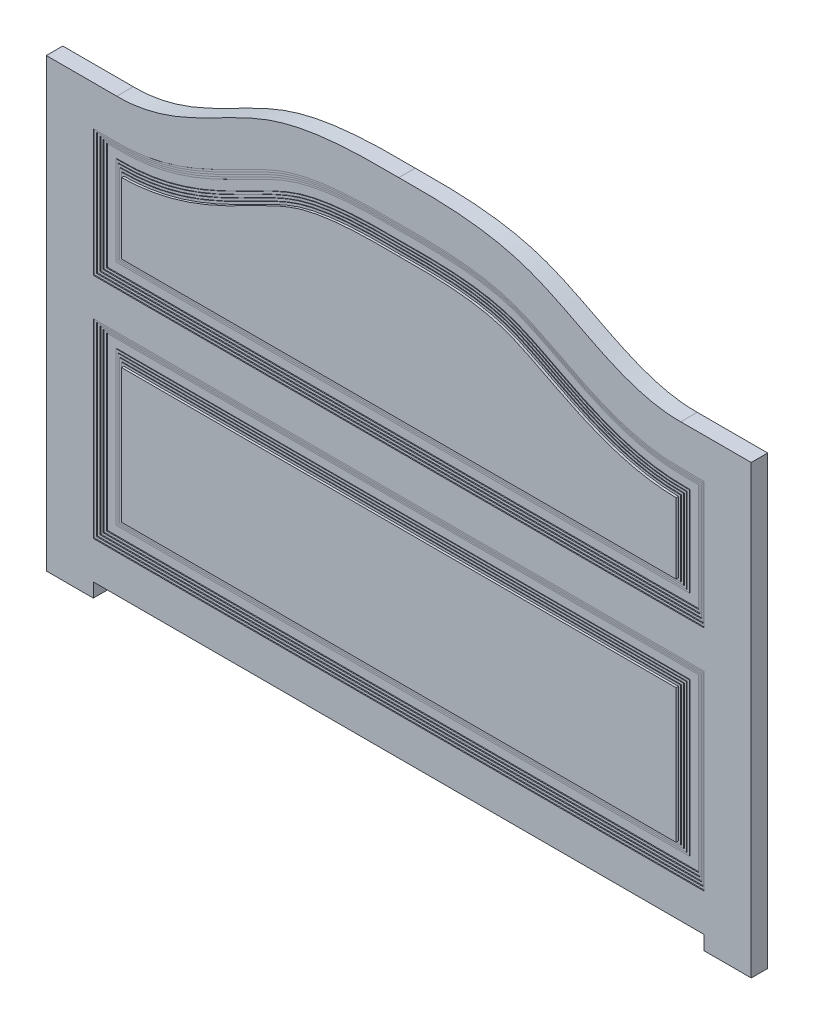
from build123d import *

# Parameters (mm, degrees)
BOSS_EXTRUDE1_DEPTH  = 35
CUT_EXTRUDE1_DEPTH   = 2
CUT_EXTRUDE2_DEPTH   = 2
CUT_EXTRUDE3_DEPTH   = 2
CUT_EXTRUDE4_DEPTH   = 2
CUT_EXTRUDE5_DEPTH   = 2
BOSS_EXTRUDE2_DEPTH  = 1.25
BOSS_EXTRUDE3_DEPTH  = 1.25
BOSS_EXTRUDE4_DEPTH  = 1.25
BOSS_EXTRUDE5_DEPTH  = 1.25
BOSS_EXTRUDE6_DEPTH  = 5
SKETCH12_W           = 1300
SKETCH12_H           = 30
CUT_EXTRUDE6_DEPTH   = 36.0000001
SKETCH13_W           = 1300
SKETCH13_H           = 405
CUT_EXTRUDE7_DEPTH   = 2
SKETCH14_W           = 1290
SKETCH14_H           = 395
CUT_EXTRUDE8_DEPTH   = 2
SKETCH15_W           = 1280
SKETCH15_H           = 385
CUT_EXTRUDE9_DEPTH   = 2
SKETCH16_W           = 1270
SKETCH16_H           = 375
CUT_EXTRUDE10_DEPTH  = 2
SKETCH17_W           = 1260
SKETCH17_H           = 365
CUT_EXTRUDE11_DEPTH  = 2
SKETCH18_W           = 1220
SKETCH18_H           = 325
BOSS_EXTRUDE7_DEPTH  = 1.25
SKETCH19_W           = 1210
SKETCH19_H           = 315
BOSS_EXTRUDE8_DEPTH  = 1.25
SKETCH20_W           = 1200
SKETCH20_H           = 305
BOSS_EXTRUDE9_DEPTH  = 1.25
SKETCH21_W           = 1190
SKETCH21_H           = 295
BOSS_EXTRUDE10_DEPTH = 1.25
SKETCH22_W           = 1180
SKETCH22_H           = 285
BOSS_EXTRUDE11_DEPTH = 5


with BuildPart() as part:
    # Sketch1 → Boss-Extrude1 (new body)
    with BuildSketch(Plane.XY):
        with BuildLine():
            Line((0, 0), (0, 150))
            add(Edge.make_bspline(
                [(0, 150), (-88.817406594, 150.972834744), (-307.790292815, 146.939990671), (-474.88994394, -1.348363378), (-600, 0)],
                knots=[0, 0, 0, 0, 0.436252435, 1, 1, 1, 1], degree=3))
            Line((-600, 0), (-750, 0))
            Line((-750, 0), (-750, -950))
            Line((-750, -950), (0, -950))
            Line((0, -950), (0, 0))
        make_face()
    boss_extrude1 = extrude(amount=BOSS_EXTRUDE1_DEPTH)

    # Mirror1: Boss-Extrude1 across plane
    add(boss_extrude1.mirror(Plane(origin=(0, 0, 0), x_dir=(0, 0, 1), z_dir=(1, 0, 0))))

    # Sketch2 → Cut-Extrude1 (cut)
    with BuildSketch(Plane.XY.offset(35)):
        with BuildLine():
            Line((-650, -355), (-650, -85))
            Line((-650, -85), (-600.427478486, -85))
            add(Edge.make_bspline(
                [(0, 64.994901319), (-6.499864474, 65.066095629), (-12.999339965, 65.125184784), (-25.996628916, 65.191640606), (-32.494485815, 65.200359117), (-51.984764082, 65.124054121), (-64.973907821, 64.937030663), (-90.938277662, 64.129866445), (-103.913521787, 63.510286532), (-123.361583263, 62.120193531), (-129.841796022, 61.579825813), (-139.557768111, 60.63399387), (-142.79703468, 60.2959783), (-149.26089955, 59.572743903), (-152.486735704, 59.187423069), (-168.583364413, 57.134249562), (-181.356982287, 55.088561066), (-206.636866058, 49.957662736), (-219.143373755, 46.873393072), (-234.562103747, 42.184405198), (-237.635079352, 41.204730045), (-243.75808105, 39.156147154), (-246.807839347, 38.086198168), (-255.925186426, 34.752209092), (-261.961183487, 32.365333669), (-273.968396946, 27.339701834), (-279.942981126, 24.699326), (-291.823088426, 19.246149426), (-297.729902726, 16.432962323), (-315.385232858, 7.823762056), (-327.069604167, 1.860632515), (-350.422387358, -10.107205823), (-362.090469323, -16.112774157), (-385.538220873, -27.833190467), (-397.317701282, -33.548531303), (-421.09610066, -44.407507465), (-433.094876365, -49.551516037), (-457.404681475, -59.026015444), (-469.715561428, -63.356895647), (-494.73157389, -70.991505865), (-507.436529994, -74.295695467), (-533.316708495, -79.678885117), (-546.491729222, -81.758410581), (-561.620746224, -83.297737299), (-563.305297505, -83.457562009), (-566.673089318, -83.753813308), (-571.726324374, -84.163461637), (-576.784220493, -84.468496437), (-586.906272008, -84.938081958), (-593.662653708, -85.063789778), (-600.427478486, -85)],
                knots=[0, 0, 0, 0, 0.03125, 0.03125, 0.0625, 0.0625, 0.125, 0.125, 0.1875, 0.1875, 0.21875, 0.21875, 0.234375, 0.234375, 0.25, 0.25, 0.3125, 0.3125, 0.375, 0.375, 0.390625, 0.390625, 0.40625, 0.40625, 0.4375, 0.4375, 0.46875, 0.46875, 0.5, 0.5, 0.5625, 0.5625, 0.625, 0.625, 0.6875, 0.6875, 0.75, 0.75, 0.8125, 0.8125, 0.875, 0.875, 0.9375, 0.9375, 0.9453125, 0.9453125, 0.953125, 0.96875, 0.96875, 1, 1, 1, 1], degree=3))
            add(Edge.make_bspline(
                [(600.427478486, -85), (587.134222228, -85.125350456), (573.97860065, -84.517793446), (547.923518621, -81.938616236), (535.024130317, -79.966611847), (509.45968606, -74.774778549), (496.79472732, -71.554431977), (477.952631083, -65.896713501), (471.697771026, -63.873215801), (462.351104985, -60.648270489), (459.241482512, -59.541696046), (453.033523317, -57.2684503), (449.935817529, -56.101953999), (434.519710085, -50.145874903), (422.380684539, -44.970816881), (398.371834421, -34.051090856), (386.502227031, -28.305963308), (362.89999974, -16.525852499), (351.167679527, -10.490235115), (327.686310086, 1.545602251), (315.937793309, 7.546948862), (298.162205757, 16.225628715), (292.21123464, 19.06398338), (283.224855611, 23.194723971), (280.219378922, 24.550442219), (274.184436702, 27.211120045), (271.160911312, 28.513439713), (262.071701262, 32.321645385), (255.986439257, 34.729396534), (246.808401626, 38.086198457), (243.740633522, 39.162332384), (237.586599575, 41.220598478), (234.50054899, 42.20382454), (219.028115751, 46.905603066), (206.515952078, 49.984961905), (181.286274834, 55.10013306), (168.568520586, 57.134722298), (142.975224901, 60.402058292), (130.099525585, 61.634002739), (110.696588611, 63.027667727), (104.213988732, 63.416228399), (91.223213634, 64.063381065), (84.712332243, 64.322037945), (65.166579635, 64.933719685), (52.134521088, 65.122688506), (32.584969424, 65.200389606), (26.06820733, 65.191871598), (13.034332123, 65.125497593), (6.517209362, 65.066285611), (0, 64.994901319)],
                knots=[0, 0, 0, 0, 0.0625, 0.0625, 0.125, 0.125, 0.1875, 0.1875, 0.21875, 0.21875, 0.234375, 0.234375, 0.25, 0.25, 0.3125, 0.3125, 0.375, 0.375, 0.4375, 0.4375, 0.5, 0.5, 0.53125, 0.53125, 0.546875, 0.546875, 0.5625, 0.5625, 0.59375, 0.59375, 0.609375, 0.609375, 0.625, 0.625, 0.6875, 0.6875, 0.75, 0.75, 0.8125, 0.8125, 0.84375, 0.84375, 0.875, 0.875, 0.9375, 0.9375, 0.96875, 0.96875, 1, 1, 1, 1], degree=3))
            Line((600.427478486, -85), (650, -85))
            Line((650, -85), (650, -355))
            Line((650, -355), (-650, -355))
        make_face()
    extrude(amount=-CUT_EXTRUDE1_DEPTH, mode=Mode.SUBTRACT)

    # Sketch3 → Cut-Extrude2 (cut)
    with BuildSketch(Plane.XY.offset(33)):
        with BuildLine():
            Line((-600.427478486, -90), (-645, -90))
            Line((-645, -90), (-645, -350))
            Line((-645, -350), (645, -350))
            Line((645, -350), (645, -90))
            Line((645, -90), (600.474624528, -89.99977772))
            add(Edge.make_bspline(
                [(600.474624528, -89.99977772), (587.283330747, -90.124166708), (574.22142551, -89.53671532), (548.339339258, -87.031949381), (535.519249318, -85.114133762), (510.101302776, -80.055869856), (491.204775132, -75.343782092), (472.530816357, -69.407215703), (463.228042857, -66.250746363), (460.132823693, -65.167201602), (453.953262909, -62.940268484), (450.874141978, -61.798715214), (435.542752146, -55.964976804), (423.468365501, -50.887796985), (399.590000138, -40.151876173), (387.786614175, -34.491860357), (364.325901096, -22.857702747), (352.669536068, -16.881491811), (329.3574474, -4.927690516), (317.700174426, 1.054811947), (294.237145996, 12.62513653), (282.432843165, 18.21754321), (264.473177128, 25.935608893), (258.444117741, 28.395740121), (249.314508964, 31.858143381), (246.256930117, 32.974208118), (240.108921248, 35.119342556), (237.018096098, 36.147365896), (221.48170474, 41.069630424), (208.793457137, 44.321213412), (192.674799168, 47.701545093), (189.434911338, 48.344133292), (182.953133154, 49.56059053), (179.710134783, 50.134763244), (169.975260873, 51.762363805), (163.477509984, 52.720929681), (143.964210576, 55.272957571), (130.928669165, 56.543619279), (104.818479635, 58.45353541), (91.743806676, 59.092388781), (65.566928559, 59.925567413), (52.464692036, 60.119386273), (32.798351339, 60.2004472), (26.240733507, 60.19241616), (13.122388172, 60.126146097), (6.561571761, 60.066471599), (0, 59.994601396)],
                knots=[0, 0, 0, 0, 0.0625, 0.0625, 0.125, 0.125, 0.1875, 0.21875, 0.21875, 0.234375, 0.234375, 0.25, 0.25, 0.3125, 0.3125, 0.375, 0.375, 0.4375, 0.4375, 0.5, 0.5, 0.5625, 0.5625, 0.59375, 0.59375, 0.609375, 0.609375, 0.625, 0.625, 0.6875, 0.6875, 0.703125, 0.703125, 0.71875, 0.71875, 0.75, 0.75, 0.8125, 0.8125, 0.875, 0.875, 0.9375, 0.9375, 0.96875, 0.96875, 1, 1, 1, 1], degree=3))
            add(Edge.make_bspline(
                [(0, 59.994601396), (-6.551716083, 60.066365894), (-13.102913006, 60.12597926), (-26.203046748, 60.192307382), (-32.752044784, 60.200454971), (-52.394560518, 60.120079641), (-65.483617124, 59.927143199), (-91.642737272, 59.096730442), (-104.71281737, 58.459641617), (-130.825947712, 56.552819967), (-143.8690242, 55.283701405), (-160.149769373, 53.156628685), (-163.404755441, 52.704032852), (-169.891335454, 51.743320988), (-179.593610165, 50.21803681), (-189.207733344, 48.423728544), (-208.304349931, 44.433399428), (-220.859576587, 41.236511254), (-236.274775521, 36.389443989), (-239.343722138, 35.377020481), (-245.452180582, 33.262343291), (-248.492010193, 32.161059435), (-257.573403808, 28.740947472), (-263.577014628, 26.306292441), (-281.47422698, 18.655577324), (-293.25509218, 13.09546435), (-310.826579214, 4.450688716), (-316.667354009, 1.51690544), (-328.326452076, -4.399815439), (-334.145655177, -7.382930432), (-351.602547222, -16.333991585), (-363.23860641, -22.305837236), (-386.641993368, -33.935444216), (-398.408408405, -39.595389429), (-422.184595457, -50.333003344), (-434.193712765, -55.412238556), (-458.552786096, -64.755189414), (-470.902266859, -69.020042211), (-489.747995962, -74.648054242), (-499.251130282, -77.270000013), (-508.886495193, -79.57555968), (-515.340783696, -81.039115577), (-518.578382515, -81.732948386), (-534.774574766, -84.998123894), (-547.80092248, -86.966086092), (-574.001590243, -89.528395002), (-587.175854245, -90.12326199), (-600.427478486, -90)],
                knots=[0, 0, 0, 0, 0.03125, 0.03125, 0.0625, 0.0625, 0.125, 0.125, 0.1875, 0.1875, 0.25, 0.25, 0.265625, 0.265625, 0.28125, 0.3125, 0.3125, 0.375, 0.375, 0.390625, 0.390625, 0.40625, 0.40625, 0.4375, 0.4375, 0.5, 0.5, 0.53125, 0.53125, 0.5625, 0.5625, 0.625, 0.625, 0.6875, 0.6875, 0.75, 0.75, 0.8125, 0.8125, 0.84375, 0.859375, 0.859375, 0.875, 0.875, 0.9375, 0.9375, 1, 1, 1, 1], degree=3))
        make_face()
    extrude(amount=-CUT_EXTRUDE2_DEPTH, mode=Mode.SUBTRACT)

    # Sketch4 → Cut-Extrude3 (cut)
    with BuildSketch(Plane.XY.offset(31)):
        with BuildLine():
            Line((-600.427478486, -95), (-640, -95))
            Line((-640, -95), (-640, -345))
            Line((-640, -345), (640, -345))
            Line((640, -345), (640, -94.999975039))
            Line((640, -94.999975039), (600.52177057, -94.99955544))
            add(Edge.make_bspline(
                [(600.52177057, -94.99955544), (587.270187276, -95.124512936), (574.165463522, -94.540719011), (548.228501892, -92.05810081), (535.396377304, -90.158729807), (509.981365194, -85.157157358), (497.398708861, -82.053840188), (472.454697339, -74.779195565), (460.093654017, -70.606363026), (444.758520601, -64.829676618), (441.697287375, -63.646379824), (435.585752702, -61.227028931), (432.533906916, -59.990347047), (423.412525699, -56.214413513), (417.372779628, -53.607665623), (399.356594076, -45.563523169), (387.484053812, -39.900390535), (363.891578652, -28.242565114), (352.172857836, -22.245234534), (328.743715524, -10.232541744), (317.035250325, -4.212929158), (293.448531292, 7.457402395), (281.573024824, 13.114090463), (263.457914807, 20.943303313), (257.368995826, 23.443215001), (248.130670941, 26.965069262), (245.033712131, 28.100961734), (238.799231642, 30.284617203), (235.661171879, 31.331211125), (230.923178819, 32.833959274), (229.339258339, 33.323692568), (226.171663236, 34.278776271), (221.416864913, 35.676010272), (216.652238575, 36.971112025), (207.110865648, 39.435362488), (200.733804854, 40.910412784), (181.561378787, 44.906961322), (168.725017542, 47.002431447), (142.971090581, 50.349498796), (130.053485318, 51.600685071), (104.15849647, 53.48184423), (91.181061034, 54.11127828), (65.183992269, 54.931627947), (52.16430697, 55.1220035), (32.614846945, 55.200433663), (26.095030283, 55.191971987), (13.050615183, 55.125356658), (6.525879882, 55.065780736), (-8.57e-07, 54.994301464)],
                knots=[0, 0, 0, 0, 0.0625, 0.0625, 0.125, 0.125, 0.1875, 0.1875, 0.25, 0.25, 0.265625, 0.265625, 0.28125, 0.28125, 0.3125, 0.3125, 0.375, 0.375, 0.4375, 0.4375, 0.5, 0.5, 0.5625, 0.5625, 0.59375, 0.59375, 0.609375, 0.609375, 0.625, 0.625, 0.6328125, 0.6328125, 0.640625, 0.65625, 0.65625, 0.6875, 0.6875, 0.75, 0.75, 0.8125, 0.8125, 0.875, 0.875, 0.9375, 0.9375, 0.96875, 0.96875, 1, 1, 1, 1], degree=3))
            add(Edge.make_bspline(
                [(-8.57e-07, 54.994301464), (-6.55136629, 55.066064308), (-13.102225898, 55.125844938), (-26.201703934, 55.19231607), (-32.75038526, 55.20049653), (-52.391992318, 55.119934011), (-65.480498541, 54.926499616), (-91.638639621, 54.09259693), (-104.708288823, 53.452468435), (-130.820645472, 51.534002379), (-143.86337376, 50.25615846), (-160.143656652, 48.110999134), (-163.395958207, 47.654771239), (-169.877870238, 46.685922789), (-173.109534009, 46.173044291), (-182.774812449, 44.543423446), (-189.178729711, 43.335743099), (-208.257045214, 39.304099781), (-220.797698578, 36.070589571), (-236.188832495, 31.156959631), (-239.252568161, 30.129859627), (-245.350666555, 27.9857152), (-248.385439785, 26.869927794), (-257.452298455, 23.407854214), (-263.446915222, 20.946833237), (-281.320558099, 13.226298349), (-293.089448031, 7.629530635), (-310.649736837, -1.050542282), (-316.48725812, -3.993071264), (-328.141783497, -9.92094136), (-333.959970964, -12.906624308), (-351.417032981, -21.857683059), (-363.057441846, -27.819382022), (-386.476295391, -39.411990346), (-398.253565357, -45.045714794), (-422.055369547, -55.720618586), (-434.0790739, -60.763786633), (-458.468206891, -70.031213221), (-470.833060149, -74.256850603), (-489.700250374, -79.828672198), (-496.042548922, -81.558373151), (-505.643471988, -83.94329854), (-508.858355059, -84.703345162), (-515.318582354, -86.150441171), (-518.556815586, -86.835902985), (-534.760226491, -90.062016117), (-547.791282051, -92.005232941), (-573.998789825, -94.534723612), (-587.175175679, -95.121616779), (-600.427478486, -95)],
                knots=[0, 0, 0, 0, 0.03125, 0.03125, 0.0625, 0.0625, 0.125, 0.125, 0.1875, 0.1875, 0.25, 0.25, 0.265625, 0.265625, 0.28125, 0.28125, 0.3125, 0.3125, 0.375, 0.375, 0.390625, 0.390625, 0.40625, 0.40625, 0.4375, 0.4375, 0.5, 0.5, 0.53125, 0.53125, 0.5625, 0.5625, 0.625, 0.625, 0.6875, 0.6875, 0.75, 0.75, 0.8125, 0.8125, 0.84375, 0.84375, 0.859375, 0.859375, 0.875, 0.875, 0.9375, 0.9375, 1, 1, 1, 1], degree=3))
        make_face()
    extrude(amount=-CUT_EXTRUDE3_DEPTH, mode=Mode.SUBTRACT)

    # Sketch5 → Cut-Extrude4 (cut)
    with BuildSketch(Plane.XY.offset(29)):
        with BuildLine():
            Line((-600.427478486, -100), (-635, -100))
            Line((-635, -100), (-635, -340))
            Line((-635, -340), (635, -340))
            Line((635, -340), (635, -99.999921896))
            Line((635, -99.999921896), (600.568916612, -99.99933316))
            add(Edge.make_bspline(
                [(600.568916612, -99.99933316), (587.265302227, -100.12478129), (574.103953031, -99.545404721), (548.045918633, -97.075426253), (535.14935047, -95.184244506), (509.599105501, -90.198523893), (496.945677091, -87.102754402), (471.855414853, -79.83814047), (459.418933799, -75.667548277), (443.987671521, -69.887837912), (440.907129328, -68.703605474), (434.756820662, -66.281754429), (431.6892047, -65.044935508), (422.52322897, -61.269020584), (416.455161389, -58.661763277), (398.357790679, -50.614247724), (386.436333014, -44.946104387), (362.754184616, -33.270105823), (350.994898897, -27.259281701), (327.489724888, -15.209323746), (315.746094546, -9.165418706), (292.088588821, 2.562651568), (280.177963655, 8.25368474), (265.030687509, 14.820202123), (261.988243003, 16.10605834), (255.872143659, 18.611821136), (252.795534266, 19.832787785), (246.634301049, 22.187180337), (243.547206418, 23.321644932), (237.358301431, 25.493503177), (234.256294136, 26.529597743), (218.709704812, 31.468953049), (206.15808015, 34.666116844), (180.885929456, 39.946301984), (168.165376434, 42.029145287), (142.597695451, 45.359891891), (129.750551002, 46.60768642), (103.962490632, 48.484720543), (91.021515504, 49.113569575), (71.560210303, 49.728061568), (65.064785238, 49.87798814), (52.060365995, 50.088333869), (45.550813003, 50.148734937), (32.536113877, 50.200467682), (26.028829298, 50.191773241), (13.014353183, 50.12489932), (6.507164364, 50.065275819), (-2.549e-06, 49.994001523)],
                knots=[0, 0, 0, 0, 0.0625, 0.0625, 0.125, 0.125, 0.1875, 0.1875, 0.25, 0.25, 0.265625, 0.265625, 0.28125, 0.28125, 0.3125, 0.3125, 0.375, 0.375, 0.4375, 0.4375, 0.5, 0.5, 0.5625, 0.5625, 0.578125, 0.578125, 0.59375, 0.59375, 0.609375, 0.609375, 0.625, 0.625, 0.6875, 0.6875, 0.75, 0.75, 0.8125, 0.8125, 0.875, 0.875, 0.90625, 0.90625, 0.9375, 0.9375, 0.96875, 0.96875, 1, 1, 1, 1], degree=3))
            add(Edge.make_bspline(
                [(-2.549e-06, 49.994001523), (-6.552182936, 50.065775423), (-13.103866919, 50.125731053), (-26.204995973, 50.192338788), (-32.754506063, 50.20053887), (-52.398607564, 50.119699913), (-65.488787882, 49.925642579), (-91.650257085, 49.087764847), (-104.721558048, 48.444232027), (-130.837102782, 46.51299475), (-143.881361475, 45.225645562), (-160.163353115, 43.060982529), (-163.413805551, 42.6007599), (-169.893186445, 41.622900505), (-173.123430951, 41.105100982), (-182.783937317, 39.459318527), (-189.183996346, 38.239026048), (-208.248081447, 34.162207816), (-220.775793186, 30.889061699), (-236.142815994, 25.903297972), (-239.201290811, 24.860515134), (-245.28904666, 22.685723881), (-248.318746531, 21.554995571), (-257.370867077, 18.04979074), (-263.356267838, 15.562169475), (-281.205254764, 7.771621137), (-292.961120656, 2.139466324), (-310.508301894, -6.573497085), (-316.341944814, -9.523796476), (-327.991411966, -15.461045476), (-333.80835205, -18.448393148), (-351.264843732, -27.396811057), (-362.909137165, -33.346489456), (-386.342186976, -44.898786855), (-398.129568354, -50.504709166), (-421.955036671, -61.114255935), (-433.99215766, -66.120201001), (-458.408486044, -75.310258904), (-470.787038184, -79.495945935), (-489.672769411, -85.010742701), (-499.194972881, -87.577538927), (-508.847214173, -89.831930828), (-515.312194224, -91.262420001), (-518.550194036, -91.939375285), (-534.75781541, -95.126148715), (-547.791173599, -97.044517636), (-574.000733006, -99.541088833), (-587.176859327, -100.119993801), (-600.427478486, -100)],
                knots=[0, 0, 0, 0, 0.03125, 0.03125, 0.0625, 0.0625, 0.125, 0.125, 0.1875, 0.1875, 0.25, 0.25, 0.265625, 0.265625, 0.28125, 0.28125, 0.3125, 0.3125, 0.375, 0.375, 0.390625, 0.390625, 0.40625, 0.40625, 0.4375, 0.4375, 0.5, 0.5, 0.53125, 0.53125, 0.5625, 0.5625, 0.625, 0.625, 0.6875, 0.6875, 0.75, 0.75, 0.8125, 0.8125, 0.84375, 0.859375, 0.859375, 0.875, 0.875, 0.9375, 0.9375, 1, 1, 1, 1], degree=3))
        make_face()
    extrude(amount=-CUT_EXTRUDE4_DEPTH, mode=Mode.SUBTRACT)

    # Sketch6 → Cut-Extrude5 (cut)
    with BuildSketch(Plane.XY.offset(27)):
        with BuildLine():
            Line((-600.427478486, -105), (-630, -105))
            Line((-630, -105), (-630, -335))
            Line((-630, -335), (630, -335))
            Line((630, -335), (630, -104.999836402))
            Line((630, -104.999836402), (600.616062654, -104.999110881))
            add(Edge.make_bspline(
                [(600.616062654, -104.999110881), (587.308618191, -105.124595126), (574.137927957, -104.554108839), (548.051685569, -102.114685846), (535.13625411, -100.245134899), (509.540388508, -95.310083092), (496.860221894, -92.243220727), (471.710467162, -85.037818502), (459.241278988, -80.897243248), (443.766724526, -75.151885439), (440.676249634, -73.97387223), (434.510983137, -71.566009958), (431.439953895, -70.337622472), (422.259075119, -66.584577133), (416.181486013, -63.991927907), (398.057178851, -55.985391971), (386.120072838, -50.340489314), (362.413409745, -38.697561527), (350.645446464, -32.696177342), (327.131629517, -20.646811229), (315.38836189, -14.593379022), (291.741280622, -2.824877882), (279.841383824, 2.898446105), (264.712497588, 9.517244118), (261.671082687, 10.815514075), (255.574271297, 13.340516962), (252.519673294, 14.566927094), (246.396230455, 16.936710954), (243.327377727, 18.08003869), (237.173371275, 20.271685258), (234.087967533, 21.318546881), (218.618944768, 26.308038118), (206.112595577, 29.535345886), (180.906681544, 34.863821224), (168.207173386, 36.965319175), (142.663357424, 40.324363241), (129.819129678, 41.582375973), (104.023528216, 43.473910706), (91.072125127, 44.107261505), (71.588141293, 44.725772353), (65.081550897, 44.876635426), (52.06552982, 45.088017828), (45.557449625, 45.148577599), (32.541182435, 45.200499131), (26.032995329, 45.191789049), (13.016544587, 45.124783955), (6.508278634, 45.064988101), (-5.053e-06, 44.993701574)],
                knots=[0, 0, 0, 0, 0.0625, 0.0625, 0.125, 0.125, 0.1875, 0.1875, 0.25, 0.25, 0.265625, 0.265625, 0.28125, 0.28125, 0.3125, 0.3125, 0.375, 0.375, 0.4375, 0.4375, 0.5, 0.5, 0.5625, 0.5625, 0.578125, 0.578125, 0.59375, 0.59375, 0.609375, 0.609375, 0.625, 0.625, 0.6875, 0.6875, 0.75, 0.75, 0.8125, 0.8125, 0.875, 0.875, 0.90625, 0.90625, 0.9375, 0.9375, 0.96875, 0.96875, 1, 1, 1, 1], degree=3))
            add(Edge.make_bspline(
                [(-5.053e-06, 44.993701574), (-6.552268816, 45.06547846), (-13.104047907, 45.125603082), (-26.205380783, 45.192352562), (-32.755001249, 45.200580558), (-52.399464186, 45.119518786), (-65.489926054, 44.924912676), (-91.652032351, 44.083300489), (-104.723686745, 43.436533991), (-130.839955497, 41.492917311), (-143.885800046, 40.196122941), (-169.935106036, 36.702102561), (-182.817165387, 34.51861707), (-208.212614707, 29.023159037), (-220.725712114, 25.710290973), (-239.135418917, 19.639224354), (-245.209634669, 17.42467407), (-257.259741001, 12.694602798), (-263.236285656, 10.181083917), (-281.061978593, 2.322366588), (-292.806282695, -3.343757071), (-310.342672326, -12.088024029), (-316.172955645, -15.045382928), (-327.818685333, -20.990830509), (-333.634993219, -23.979336078), (-351.092661501, -32.923805564), (-362.741910535, -38.860782523), (-386.191026528, -50.372217988), (-397.989366135, -55.950352639), (-421.840030116, -66.495312462), (-433.891284306, -71.464713433), (-458.336245594, -80.579274181), (-470.729234574, -84.726162375), (-489.634772205, -90.185791946), (-495.989193964, -91.879124916), (-505.606800991, -94.212194802), (-508.827625935, -94.955520551), (-515.296587385, -96.369751242), (-518.535124411, -97.038613986), (-534.748522866, -100.187592377), (-547.785479262, -102.082126606), (-573.999792706, -104.547158361), (-587.177068041, -105.118426473), (-600.427478486, -105)],
                knots=[0, 0, 0, 0, 0.03125, 0.03125, 0.0625, 0.0625, 0.125, 0.125, 0.1875, 0.1875, 0.25, 0.25, 0.3125, 0.3125, 0.375, 0.375, 0.40625, 0.40625, 0.4375, 0.4375, 0.5, 0.5, 0.53125, 0.53125, 0.5625, 0.5625, 0.625, 0.625, 0.6875, 0.6875, 0.75, 0.75, 0.8125, 0.8125, 0.84375, 0.84375, 0.859375, 0.859375, 0.875, 0.875, 0.9375, 0.9375, 1, 1, 1, 1], degree=3))
        make_face()
    extrude(amount=-CUT_EXTRUDE5_DEPTH, mode=Mode.SUBTRACT)

    # Sketch7 → Boss-Extrude2 (add)
    with BuildSketch(Plane.XY.offset(25)):
        with BuildLine():
            Line((-600.427478486, -125), (-610, -125))
            Line((-610, -125), (-610, -315))
            Line((-610, -315), (610, -315))
            Line((610, -315), (610, -124.999342586))
            Line((610, -124.999342586), (600.804646822, -124.998221761))
            add(Edge.make_bspline(
                [(600.804646822, -124.998221761), (587.624538649, -125.122505273), (574.558871094, -124.598145969), (548.643380979, -122.326030413), (535.793680251, -120.577583615), (510.29587706, -115.938042707), (497.648057139, -113.045347165), (478.81449699, -107.923165782), (472.559706137, -106.085054902), (460.093597329, -102.162431266), (453.880555745, -100.077631994), (435.312069999, -93.484690969), (423.125367995, -88.67090336), (399.046155241, -78.403055015), (387.154418037, -72.947310743), (363.5618366, -61.620365802), (351.862200045, -55.746536758), (334.361770829, -46.829094627), (328.536173343, -43.839466364), (316.883368073, -37.863714463), (311.055260038, -34.878220675), (299.37807573, -28.963777218), (293.529012702, -26.034634221), (281.790519979, -20.284595634), (275.900504989, -17.46526957), (264.052299851, -12.009436199), (258.094565633, -9.371706265), (246.08150911, -4.357938971), (240.025723879, -1.983142994), (230.83843841, 1.301216388), (227.75803754, 2.34780805), (221.560434629, 4.342305216), (218.44373856, 5.291567537), (209.043071178, 8.003721198), (202.708471775, 9.630848069), (189.922145756, 12.571013044), (183.470923641, 13.88540402), (173.717993398, 15.652928302), (170.458172066, 16.207156498), (163.940636069, 17.248139959), (160.680047382, 17.735423951), (144.36879782, 20.020347595), (131.293484109, 21.368341533), (105.10551467, 23.383244381), (91.992865384, 24.050270784), (65.741953536, 24.917160309), (52.603673231, 25.116699806), (32.884446758, 25.200677895), (26.309397579, 25.192672279), (13.156494731, 25.125509656), (6.578542667, 25.064558027), (-1.8234e-05, 24.992501739)],
                knots=[0, 0, 0, 0, 0.0625, 0.0625, 0.125, 0.125, 0.1875, 0.1875, 0.21875, 0.21875, 0.25, 0.25, 0.3125, 0.3125, 0.375, 0.375, 0.4375, 0.4375, 0.46875, 0.46875, 0.5, 0.5, 0.53125, 0.53125, 0.5625, 0.5625, 0.59375, 0.59375, 0.625, 0.625, 0.640625, 0.640625, 0.65625, 0.65625, 0.6875, 0.6875, 0.71875, 0.71875, 0.734375, 0.734375, 0.75, 0.75, 0.8125, 0.8125, 0.875, 0.875, 0.9375, 0.9375, 0.96875, 0.96875, 1, 1, 1, 1], degree=3))
            add(Edge.make_bspline(
                [(-1.8234e-05, 24.992501739), (-6.565574437, 25.064432035), (-13.130654134, 25.125323344), (-26.258459201, 25.192564251), (-32.821264094, 25.200756156), (-52.505036765, 25.117792486), (-65.621383238, 24.919577174), (-91.833975055, 24.057472477), (-104.930222224, 23.393625382), (-131.093426644, 21.387384471), (-144.160372921, 20.044736433), (-170.252843407, 16.399833404), (-183.142121705, 14.112912273), (-202.159591714, 9.765491002), (-208.44584539, 8.162164678), (-217.783192758, 5.48894437), (-220.880300803, 4.55315933), (-227.041698794, 2.585940817), (-230.105471695, 1.553000418), (-239.247624414, -1.689115154), (-245.278319831, -4.037266625), (-257.246936165, -9.003961068), (-263.185331127, -11.621122434), (-274.998934032, -17.039603883), (-280.873687644, -19.842248114), (-292.58328338, -25.5638587), (-298.418592774, -28.481463197), (-310.068999691, -34.375579735), (-315.883782923, -37.351780971), (-327.509295322, -43.311419479), (-333.320551376, -46.294922035), (-350.774481887, -55.195925164), (-362.437916727, -61.062452842), (-385.935432734, -72.376520903), (-397.768264038, -77.827130066), (-421.695396403, -88.086362662), (-433.788749695, -92.897313149), (-458.313218232, -101.689908438), (-470.743633317, -105.673272344), (-489.693060186, -110.902388765), (-496.060057824, -112.521381055), (-505.692440459, -114.748814656), (-508.92000329, -115.458416854), (-515.387621994, -116.804912643), (-518.625231505, -117.441340653), (-534.832580801, -120.43646537), (-547.860188923, -122.234473501), (-574.045299258, -124.571940846), (-587.202704853, -125.112336198), (-600.427478486, -125)],
                knots=[0, 0, 0, 0, 0.03125, 0.03125, 0.0625, 0.0625, 0.125, 0.125, 0.1875, 0.1875, 0.25, 0.25, 0.3125, 0.3125, 0.34375, 0.34375, 0.359375, 0.359375, 0.375, 0.375, 0.40625, 0.40625, 0.4375, 0.4375, 0.46875, 0.46875, 0.5, 0.5, 0.53125, 0.53125, 0.5625, 0.5625, 0.625, 0.625, 0.6875, 0.6875, 0.75, 0.75, 0.8125, 0.8125, 0.84375, 0.84375, 0.859375, 0.859375, 0.875, 0.875, 0.9375, 0.9375, 1, 1, 1, 1], degree=3))
        make_face()
    extrude(amount=BOSS_EXTRUDE2_DEPTH)

    # Sketch8 → Boss-Extrude3 (add)
    with BuildSketch(Plane.XY.offset(26.25)):
        with BuildLine():
            Line((-600.427478486, -130), (-605, -130))
            Line((-605, -130), (-605, -310))
            Line((-605, -310), (605, -310))
            Line((605, -310), (605, -129.998733171))
            Line((605, -129.998733171), (600.851792864, -129.997999481))
            add(Edge.make_bspline(
                [(600.851792864, -129.997999481), (574.504752286, -130.246442262), (548.598104551, -127.931637276), (510.323468511, -121.052562295), (497.662895129, -118.191244676), (478.806023378, -113.119407109), (472.542762707, -111.2986323), (463.179574681, -108.382947112), (460.063793369, -107.380312585), (453.842404398, -105.315829129), (450.734482152, -104.25314222), (435.252705283, -98.808732444), (423.057696882, -94.034575357), (398.961836677, -83.839548512), (387.061855144, -78.416765436), (363.456446556, -67.143465053), (351.752447638, -61.289807942), (334.251129263, -52.389106543), (328.426325096, -49.40248827), (316.777170609, -43.428253925), (310.95257478, -40.440301219), (299.284377051, -34.514729838), (287.597308907, -28.638962995), (275.832975969, -22.967120503), (264.002071517, -17.470979678), (258.053852514, -14.809390357), (246.060974542, -9.740744949), (240.016333469, -7.333641626), (230.845467965, -3.997219365), (227.770660456, -2.932196149), (221.582696487, -0.903363803), (218.469836617, 0.061228118), (209.078889691, 2.816791245), (202.747970526, 4.468323087), (189.964348571, 7.449964221), (183.512150394, 8.781405334), (173.755126308, 10.570783937), (170.495920557, 11.131271727), (163.978073346, 12.183809651), (160.717263635, 12.676255661), (144.404626422, 14.984468034), (131.327332577, 16.343554397), (105.134362166, 18.373421751), (92.018698493, 19.044433961), (65.761137988, 19.916027314), (52.619226545, 20.116346452), (32.894307972, 20.200710992), (26.317320323, 20.192701878), (13.160485816, 20.12541036), (6.580535905, 20.064279937), (-2.4497e-05, 19.992201748)],
                knots=[0, 0, 0, 0, 0.125, 0.125, 0.1875, 0.1875, 0.21875, 0.21875, 0.234375, 0.234375, 0.25, 0.25, 0.3125, 0.3125, 0.375, 0.375, 0.4375, 0.4375, 0.46875, 0.46875, 0.5, 0.5, 0.53125, 0.5625, 0.5625, 0.59375, 0.59375, 0.625, 0.625, 0.640625, 0.640625, 0.65625, 0.65625, 0.6875, 0.6875, 0.71875, 0.71875, 0.734375, 0.734375, 0.75, 0.75, 0.8125, 0.8125, 0.875, 0.875, 0.9375, 0.9375, 0.96875, 0.96875, 1, 1, 1, 1], degree=3))
            add(Edge.make_bspline(
                [(-2.4497e-05, 19.992201748), (-6.568214712, 20.064162732), (-13.135933037, 20.125239258), (-26.268994587, 20.192609004), (-32.834420057, 20.200799265), (-52.526015721, 20.117405447), (-65.647526449, 19.918347655), (-91.870215537, 19.051252133), (-104.971393199, 18.383198322), (-131.144013738, 16.361237684), (-144.216107743, 15.0068115), (-170.315333831, 11.323144816), (-183.20184304, 9.009972085), (-202.207282484, 4.6029766), (-208.48783426, 2.976209682), (-217.813439045, 0.260883102), (-220.906194895, -0.689824323), (-227.05724977, -2.690812916), (-230.115370564, -3.741609134), (-239.240742062, -7.035572229), (-245.260403226, -9.41626392), (-257.209352907, -14.438807237), (-263.138751398, -17.080341064), (-274.936330213, -22.540317699), (-280.803971984, -25.360316826), (-292.502141222, -31.10756843), (-298.332672723, -34.03480925), (-309.975708736, -39.941385499), (-315.787811892, -42.920627825), (-327.410643986, -48.880353033), (-333.221578228, -51.861404079), (-350.677600612, -60.747282655), (-362.346058697, -66.594464931), (-385.858237568, -77.856519345), (-397.700526037, -83.274924496), (-421.648072439, -93.463083574), (-433.752295031, -98.235391315), (-458.297132683, -106.950247397), (-470.737017317, -110.894597436), (-489.697647875, -116.069148027), (-496.067871893, -117.670632065), (-505.704146889, -119.87321075), (-508.932997876, -120.574833596), (-515.400964186, -121.905562202), (-518.638682857, -122.534460665), (-534.846233179, -125.493896368), (-547.8729023, -127.269590203), (-574.053607984, -129.577625824), (-587.207546963, -130.110920211), (-600.427478486, -130)],
                knots=[0, 0, 0, 0, 0.03125, 0.03125, 0.0625, 0.0625, 0.125, 0.125, 0.1875, 0.1875, 0.25, 0.25, 0.3125, 0.3125, 0.34375, 0.34375, 0.359375, 0.359375, 0.375, 0.375, 0.40625, 0.40625, 0.4375, 0.4375, 0.46875, 0.46875, 0.5, 0.5, 0.53125, 0.53125, 0.5625, 0.5625, 0.625, 0.625, 0.6875, 0.6875, 0.75, 0.75, 0.8125, 0.8125, 0.84375, 0.84375, 0.859375, 0.859375, 0.875, 0.875, 0.9375, 0.9375, 1, 1, 1, 1], degree=3))
        make_face()
    extrude(amount=BOSS_EXTRUDE3_DEPTH)

    # Sketch9 → Boss-Extrude4 (add)
    with BuildSketch(Plane.XY.offset(27.5)):
        with BuildLine():
            Line((-600, -135.003495455), (-600, -305))
            Line((-600, -305), (600, -305))
            Line((600, -305), (600, -135.005272935))
            add(Edge.make_bspline(
                [(600, -135.005272935), (573.707497705, -135.195821941), (547.841358267, -132.866212798), (509.611011823, -126.009348573), (496.962464786, -123.162778938), (478.120253877, -118.120913133), (468.731847851, -115.406699484), (459.389893949, -112.41791525), (453.171878544, -110.36655684), (450.065795928, -109.310705881), (434.600676275, -103.904227333), (422.416747854, -99.162972026), (398.341789603, -89.032808817), (386.451704544, -83.641811857), (362.868207759, -72.424937062), (351.176362147, -66.595596266), (333.697517023, -57.721294844), (327.880997521, -54.741608339), (316.250116715, -48.777463157), (310.435740421, -45.792238057), (298.789941932, -39.866606475), (292.958571613, -36.926114945), (281.259130837, -31.141849659), (275.391380636, -28.297231917), (263.591740835, -22.777026311), (257.660274871, -20.10032202), (245.703049202, -14.995410614), (239.677636701, -12.566288496), (230.536788979, -9.193332297), (227.472297662, -8.115243105), (221.30443923, -6.061516129), (218.201090146, -5.085830823), (208.83746217, -2.299978965), (202.523270724, -0.631890958), (189.770649438, 2.37687318), (183.332753049, 3.718955145), (175.218823895, 5.221152094), (173.591845991, 5.512938169), (170.337759783, 6.07838191), (165.45515355, 6.899655811), (160.56830392, 7.643666159), (144.270232425, 9.967608937), (131.204664591, 11.333134134), (105.035454466, 13.370926903), (91.931826983, 14.04346409), (65.698643854, 14.916439919), (52.569074824, 15.11663485), (32.862848037, 15.200739889), (26.292120719, 15.19263112), (13.14785096, 15.125155979), (6.574205326, 15.063910675), (-3.1458e-05, 14.99190175)],
                knots=[0, 0, 0, 0, 0.125, 0.125, 0.1875, 0.1875, 0.21875, 0.234375, 0.234375, 0.25, 0.25, 0.3125, 0.3125, 0.375, 0.375, 0.4375, 0.4375, 0.46875, 0.46875, 0.5, 0.5, 0.53125, 0.53125, 0.5625, 0.5625, 0.59375, 0.59375, 0.625, 0.625, 0.640625, 0.640625, 0.65625, 0.65625, 0.6875, 0.6875, 0.71875, 0.71875, 0.7265625, 0.7265625, 0.734375, 0.75, 0.75, 0.8125, 0.8125, 0.875, 0.875, 0.9375, 0.9375, 0.96875, 0.96875, 1, 1, 1, 1], degree=3))
            add(Edge.make_bspline(
                [(-3.1458e-05, 14.99190175), (-6.571259238, 15.063896013), (-13.142004077, 15.125158291), (-26.28101731, 15.192651099), (-32.849373528, 15.200833246), (-52.549563957, 15.116975319), (-65.676542462, 14.917031305), (-91.909244644, 14.044816595), (-105.014964904, 13.372469964), (-131.19521204, 11.334594487), (-144.269711617, 9.968459023), (-160.58497014, 7.641550072), (-163.843681399, 7.145281247), (-170.332725295, 6.088553767), (-173.565673721, 5.527729238), (-183.227158872, 3.740469977), (-189.618410872, 2.40946106), (-202.286881634, -0.572391051), (-211.701803476, -3.051197789), (-220.966030392, -5.952665531), (-227.105703824, -7.989288452), (-230.157410182, -9.058450964), (-239.263083416, -12.404621525), (-245.268854142, -14.816807536), (-257.190970769, -19.891993489), (-263.107116486, -22.555554895), (-274.879233106, -28.051452783), (-280.73473921, -30.885092905), (-292.410614575, -36.650923074), (-298.23070238, -39.583902535), (-309.854751409, -45.495092415), (-315.658635246, -48.473420643), (-327.267521711, -54.42595991), (-333.072498822, -57.400895981), (-350.513214829, -66.261297218), (-362.174604313, -72.082690345), (-385.675094723, -83.281575078), (-397.512645302, -88.662939264), (-421.449246327, -98.772472843), (-433.547207981, -103.503361908), (-458.074430719, -112.137594448), (-470.502948701, -116.042794099), (-489.440139064, -121.165184819), (-495.801486353, -122.750376009), (-505.422547725, -124.930729411), (-508.645409088, -125.62522052), (-515.105512231, -126.943469922), (-518.339187158, -127.566576338), (-534.525935562, -130.499462373), (-547.534099086, -132.261614555), (-573.673649578, -134.561005525), (-586.804942076, -135.099183384), (-600, -135.003495455)],
                knots=[0, 0, 0, 0, 0.03125, 0.03125, 0.0625, 0.0625, 0.125, 0.125, 0.1875, 0.1875, 0.25, 0.25, 0.265625, 0.265625, 0.28125, 0.28125, 0.3125, 0.3125, 0.34375, 0.359375, 0.359375, 0.375, 0.375, 0.40625, 0.40625, 0.4375, 0.4375, 0.46875, 0.46875, 0.5, 0.5, 0.53125, 0.53125, 0.5625, 0.5625, 0.625, 0.625, 0.6875, 0.6875, 0.75, 0.75, 0.8125, 0.8125, 0.84375, 0.84375, 0.859375, 0.859375, 0.875, 0.875, 0.9375, 0.9375, 1, 1, 1, 1], degree=3))
        make_face()
    extrude(amount=BOSS_EXTRUDE4_DEPTH)

    # Sketch10 → Boss-Extrude5 (add)
    with BuildSketch(Plane.XY.offset(28.75)):
        with BuildLine():
            Line((-595, -140.009504788), (-595, -300))
            Line((-595, -300), (595, -300))
            Line((595, -300), (595, -140.011234525))
            add(Edge.make_bspline(
                [(595, -140.011234525), (568.905693645, -139.885305652), (543.250645957, -137.314714795), (505.352208044, -130.20787559), (492.816676317, -127.2975194), (474.147243582, -122.186970049), (467.946416655, -120.359248196), (458.676860648, -117.441328302), (455.592279708, -116.439352622), (449.433299087, -114.37873822), (446.356700091, -113.319392432), (431.030879979, -107.897080929), (418.953285373, -103.158364689), (395.083981293, -93.054902511), (383.292735781, -87.689140591), (359.902366863, -76.53690881), (348.304373369, -70.747964676), (330.964443083, -61.939598896), (325.193874563, -58.982874852), (313.654570865, -53.065412123), (307.88553066, -50.10396017), (296.330397866, -44.225911943), (290.544702066, -41.309441432), (278.938456457, -35.573196748), (273.118165158, -32.752705382), (261.416657626, -27.280748194), (255.535824096, -24.628220633), (243.684471984, -19.571980955), (237.71427872, -17.167366303), (228.660843298, -13.832731874), (225.62629202, -12.767627791), (219.520093048, -10.740337124), (216.448549936, -9.777860395), (207.183182824, -7.031193275), (200.938289702, -5.388685203), (188.331663689, -2.427820514), (181.970384726, -1.108204547), (172.353629752, 0.663598574), (169.135525216, 1.219466332), (162.675932345, 2.266327601), (159.435218975, 2.757085452), (143.240731701, 5.053311723), (130.26170035, 6.399512758), (104.270920767, 8.406942964), (91.259161657, 9.067944377), (65.213426176, 9.924798996), (52.179428756, 10.1202115), (32.618277909, 10.200727616), (26.096196998, 10.192031172), (13.049621346, 10.124101483), (6.525040821, 10.063072244), (-3.8418e-05, 9.991601751)],
                knots=[0, 0, 0, 0, 0.125, 0.125, 0.1875, 0.1875, 0.21875, 0.21875, 0.234375, 0.234375, 0.25, 0.25, 0.3125, 0.3125, 0.375, 0.375, 0.4375, 0.4375, 0.46875, 0.46875, 0.5, 0.5, 0.53125, 0.53125, 0.5625, 0.5625, 0.59375, 0.59375, 0.625, 0.625, 0.640625, 0.640625, 0.65625, 0.65625, 0.6875, 0.6875, 0.71875, 0.71875, 0.734375, 0.734375, 0.75, 0.75, 0.8125, 0.8125, 0.875, 0.875, 0.9375, 0.9375, 0.96875, 0.96875, 1, 1, 1, 1], degree=3))
            add(Edge.make_bspline(
                [(-3.8418e-05, 9.991601751), (-6.525404182, 10.063093551), (-13.050283191, 10.124163007), (-26.097509323, 10.19208931), (-32.619943953, 10.20081985), (-52.182265447, 10.120328726), (-65.217190227, 9.924859204), (-91.265280443, 9.06801036), (-104.278451019, 8.406741105), (-130.272788434, 6.398940486), (-143.253949368, 5.052282674), (-159.451726365, 2.754990755), (-162.692686564, 2.264120552), (-169.146865174, 1.218244269), (-172.362109664, 0.663009176), (-181.969585381, -1.107012545), (-188.323631525, -2.42591746), (-200.9147543, -5.382665066), (-207.151246189, -7.022102162), (-216.402699728, -9.762880444), (-219.469306117, -10.723403248), (-225.564976674, -12.746814264), (-228.594162602, -13.809370479), (-237.631122342, -17.135003517), (-243.589609865, -19.532468002), (-255.415992813, -24.574412129), (-261.283623526, -27.219613555), (-272.95821017, -32.675456782), (-278.764693476, -35.487387276), (-290.342416007, -41.2073474), (-296.113341596, -44.116232213), (-307.639048506, -49.978021999), (-313.393776111, -52.931074759), (-324.904623878, -58.833361152), (-330.66055497, -61.783213156), (-347.953001271, -70.570010313), (-359.514129601, -76.344298196), (-382.805751362, -87.461723653), (-394.535030188, -92.807953226), (-418.241911913, -102.868257335), (-430.218858163, -107.584003496), (-454.486403013, -116.217035515), (-466.776672998, -120.135157926), (-485.48995984, -125.304941663), (-491.774005712, -126.91037943), (-501.274540753, -129.128968462), (-504.453805034, -129.836882588), (-510.837957889, -131.187479443), (-514.045633074, -131.83056104), (-530.092836272, -134.86678431), (-542.988672919, -136.72968196), (-568.902010219, -139.269549422), (-581.919505962, -139.946567099), (-595, -140.009504788)],
                knots=[0, 0, 0, 0, 0.03125, 0.03125, 0.0625, 0.0625, 0.125, 0.125, 0.1875, 0.1875, 0.25, 0.25, 0.265625, 0.265625, 0.28125, 0.28125, 0.3125, 0.3125, 0.34375, 0.34375, 0.359375, 0.359375, 0.375, 0.375, 0.40625, 0.40625, 0.4375, 0.4375, 0.46875, 0.46875, 0.5, 0.5, 0.53125, 0.53125, 0.5625, 0.5625, 0.625, 0.625, 0.6875, 0.6875, 0.75, 0.75, 0.8125, 0.8125, 0.84375, 0.84375, 0.859375, 0.859375, 0.875, 0.875, 0.9375, 0.9375, 1, 1, 1, 1], degree=3))
        make_face()
    extrude(amount=BOSS_EXTRUDE5_DEPTH)

    # Sketch11 → Boss-Extrude6 (add)
    with BuildSketch(Plane.XY.offset(30)):
        with BuildLine():
            Line((-590, -144.956226055), (-590, -295))
            Line((-590, -295), (590, -295))
            Line((590, -295), (590, -144.957865358))
            add(Edge.make_bspline(
                [(590, -144.957865358), (564.119701119, -144.528245117), (538.680738726, -141.729706796), (501.108310182, -134.386404513), (488.681647254, -131.415403792), (470.175831556, -126.238685043), (464.02958284, -124.393111272), (454.841910246, -121.454595098), (451.784626999, -120.446779452), (445.680237461, -118.376522323), (442.631397369, -117.313451406), (427.449515132, -111.879227879), (415.481008367, -107.145423067), (391.821256698, -97.072492647), (380.130099267, -91.733176069), (356.934329113, -80.64727669), (345.430452811, -74.89908613), (328.229552672, -66.156910823), (322.504932786, -63.223174042), (311.057187521, -57.352437653), (305.333713474, -54.414887041), (293.869165329, -48.584396781), (288.128970965, -45.691860221), (276.614959379, -40.003188469), (270.841348376, -37.206462017), (259.235317644, -31.781621841), (253.403247911, -29.152504631), (241.652358013, -24.142995653), (235.733847162, -21.761717045), (226.760584481, -18.463600487), (223.753226002, -17.410879269), (217.702461118, -15.408791204), (214.659245918, -14.458876147), (205.480657655, -11.749456341), (199.296004965, -10.131243075), (186.814699922, -7.215935017), (180.518424687, -5.917758974), (167.830501568, -3.594853426), (161.436927822, -2.570768723), (142.142724696, 0.146316782), (129.258883754, 1.471053443), (103.462005514, 3.445180516), (90.548935397, 4.093811793), (64.703013251, 4.933495329), (51.770133257, 5.123900719), (32.361785381, 5.200683144), (25.890827468, 5.1913811), (12.946759585, 5.122997377), (6.473575814, 5.062208615), (-4.5379e-05, 4.991301752)],
                knots=[0, 0, 0, 0, 0.125, 0.125, 0.1875, 0.1875, 0.21875, 0.21875, 0.234375, 0.234375, 0.25, 0.25, 0.3125, 0.3125, 0.375, 0.375, 0.4375, 0.4375, 0.46875, 0.46875, 0.5, 0.5, 0.53125, 0.53125, 0.5625, 0.5625, 0.59375, 0.59375, 0.625, 0.625, 0.640625, 0.640625, 0.65625, 0.65625, 0.6875, 0.6875, 0.71875, 0.71875, 0.75, 0.75, 0.8125, 0.8125, 0.875, 0.875, 0.9375, 0.9375, 0.96875, 0.96875, 1, 1, 1, 1], degree=3))
            add(Edge.make_bspline(
                [(-4.5379e-05, 4.991301752), (-6.477039184, 5.06226359), (-12.953551559, 5.12311528), (-25.904036319, 5.19147822), (-32.378093883, 5.200778294), (-51.795272731, 5.123806503), (-64.733418269, 4.933042791), (-90.587849635, 4.092456141), (-103.504150165, 3.442941926), (-129.304528417, 1.467226702), (-142.188624551, 0.141412323), (-158.264786435, -2.123986669), (-161.481807448, -2.60815162), (-167.895616673, -3.641361255), (-171.09055969, -4.190050048), (-180.636733545, -5.939799269), (-186.949375179, -7.244365538), (-199.456199207, -10.171235207), (-205.649846073, -11.794975027), (-214.835407588, -14.511976197), (-217.879787437, -15.464512839), (-223.930358367, -17.47201789), (-226.936656419, -18.526699379), (-235.904236384, -21.828381262), (-241.815575259, -24.2093413), (-253.547224489, -29.215422498), (-259.367222106, -31.841382502), (-270.946515944, -37.256118739), (-276.705332124, -40.046182567), (-288.187838646, -45.720526452), (-293.911195628, -48.605700662), (-305.341810634, -54.419230491), (-311.049012167, -57.347737635), (-322.464706404, -63.201288676), (-328.173004823, -66.126891545), (-345.321468774, -74.842842027), (-356.785272172, -80.572138966), (-379.874802071, -91.612549937), (-391.499635991, -96.92596915), (-414.986121879, -106.941200844), (-426.847479919, -111.643772422), (-450.868657046, -120.278109527), (-463.028445034, -124.209955367), (-487.699757238, -131.165252409), (-500.211323112, -134.188596026), (-516.101656639, -137.319862243), (-519.289805838, -137.9131211), (-532.046474619, -140.145247753), (-541.646701436, -141.507099279), (-564.126235076, -143.930942781), (-577.031921528, -144.74123703), (-590, -144.956226055)],
                knots=[0, 0, 0, 0, 0.03125, 0.03125, 0.0625, 0.0625, 0.125, 0.125, 0.1875, 0.1875, 0.25, 0.25, 0.265625, 0.265625, 0.28125, 0.28125, 0.3125, 0.3125, 0.34375, 0.34375, 0.359375, 0.359375, 0.375, 0.375, 0.40625, 0.40625, 0.4375, 0.4375, 0.46875, 0.46875, 0.5, 0.5, 0.53125, 0.53125, 0.5625, 0.5625, 0.625, 0.625, 0.6875, 0.6875, 0.75, 0.75, 0.8125, 0.8125, 0.875, 0.875, 0.890625, 0.890625, 0.9375, 0.9375, 1, 1, 1, 1], degree=3))
        make_face()
    extrude(amount=BOSS_EXTRUDE6_DEPTH)

    # Sketch12 → Cut-Extrude6 (cut, through all)
    with BuildSketch(Plane.XY.offset(35)):
        with Locations((0, -935)):
            Rectangle(SKETCH12_W, SKETCH12_H)
    extrude(amount=-CUT_EXTRUDE6_DEPTH, mode=Mode.SUBTRACT)

    # Sketch13 → Cut-Extrude7 (cut)
    with BuildSketch(Plane.XY.offset(35)):
        with Locations((0, -637.5)):
            Rectangle(SKETCH13_W, SKETCH13_H)
    extrude(amount=-CUT_EXTRUDE7_DEPTH, mode=Mode.SUBTRACT)

    # Sketch14 → Cut-Extrude8 (cut)
    with BuildSketch(Plane.XY.offset(33)):
        with Locations((0, -637.5)):
            Rectangle(SKETCH14_W, SKETCH14_H)
    extrude(amount=-CUT_EXTRUDE8_DEPTH, mode=Mode.SUBTRACT)

    # Sketch15 → Cut-Extrude9 (cut)
    with BuildSketch(Plane.XY.offset(31)):
        with Locations((0, -637.5)):
            Rectangle(SKETCH15_W, SKETCH15_H)
    extrude(amount=-CUT_EXTRUDE9_DEPTH, mode=Mode.SUBTRACT)

    # Sketch16 → Cut-Extrude10 (cut)
    with BuildSketch(Plane.XY.offset(29)):
        with Locations((0, -637.5)):
            Rectangle(SKETCH16_W, SKETCH16_H)
    extrude(amount=-CUT_EXTRUDE10_DEPTH, mode=Mode.SUBTRACT)

    # Sketch17 → Cut-Extrude11 (cut)
    with BuildSketch(Plane.XY.offset(27)):
        with Locations((0, -637.5)):
            Rectangle(SKETCH17_W, SKETCH17_H)
    extrude(amount=-CUT_EXTRUDE11_DEPTH, mode=Mode.SUBTRACT)

    # Sketch18 → Boss-Extrude7 (add)
    with BuildSketch(Plane.XY.offset(25)):
        with Locations((0, -637.5)):
            Rectangle(SKETCH18_W, SKETCH18_H)
    extrude(amount=BOSS_EXTRUDE7_DEPTH)

    # Sketch19 → Boss-Extrude8 (add)
    with BuildSketch(Plane.XY.offset(26.25)):
        with Locations((0, -637.5)):
            Rectangle(SKETCH19_W, SKETCH19_H)
    extrude(amount=BOSS_EXTRUDE8_DEPTH)

    # Sketch20 → Boss-Extrude9 (add)
    with BuildSketch(Plane.XY.offset(27.5)):
        with Locations((0, -637.5)):
            Rectangle(SKETCH20_W, SKETCH20_H)
    extrude(amount=BOSS_EXTRUDE9_DEPTH)

    # Sketch21 → Boss-Extrude10 (add)
    with BuildSketch(Plane.XY.offset(28.75)):
        with Locations((0, -637.5)):
            Rectangle(SKETCH21_W, SKETCH21_H)
    extrude(amount=BOSS_EXTRUDE10_DEPTH)

    # Sketch22 → Boss-Extrude11 (add)
    with BuildSketch(Plane.XY.offset(30)):
        with Locations((0, -637.5)):
            Rectangle(SKETCH22_W, SKETCH22_H)
    extrude(amount=BOSS_EXTRUDE11_DEPTH)


solid = part.part
